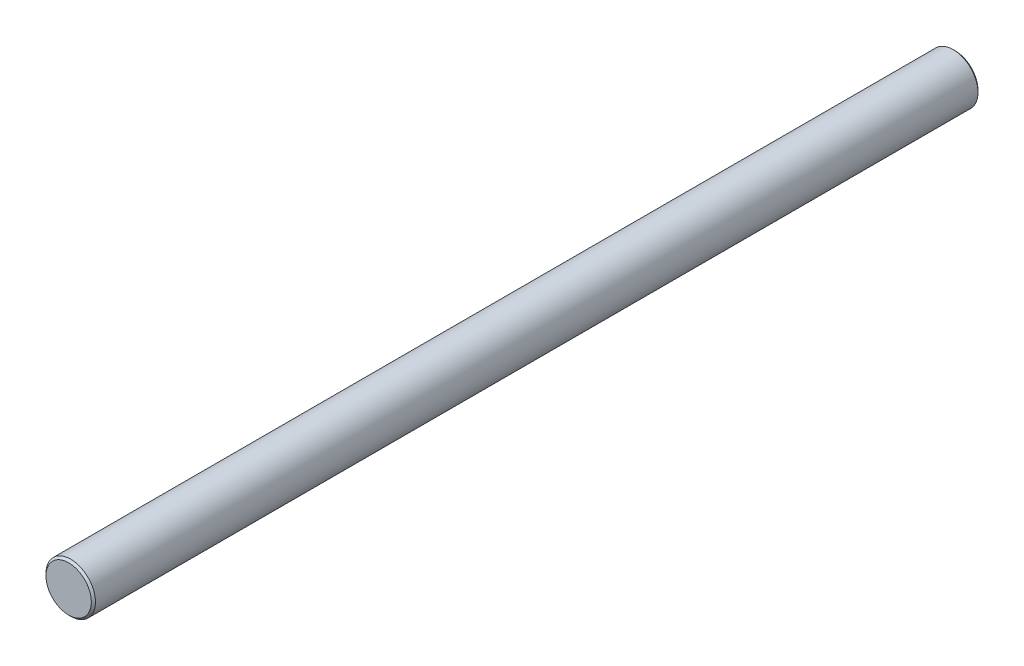
from build123d import *

# Parameters (mm, degrees)
SKETCH2_R           = 6
BOSS_EXTRUDE1_DEPTH = 107.5
CHAMFER1_SIZE       = 0.5


with BuildPart() as part:
    # Sketch2 → Boss-Extrude1 (new body, symmetric)
    with BuildSketch(Plane.XY):
        Circle(SKETCH2_R)
    extrude(amount=BOSS_EXTRUDE1_DEPTH, both=True)

    # Chamfer1
    chamfer1_edges = [part.edges().sort_by_distance(p)[0] for p in [
        (-6, 0, -107.5),
        (-6, 0, 107.5),
    ]]
    chamfer(chamfer1_edges, length=CHAMFER1_SIZE)


solid = part.part
